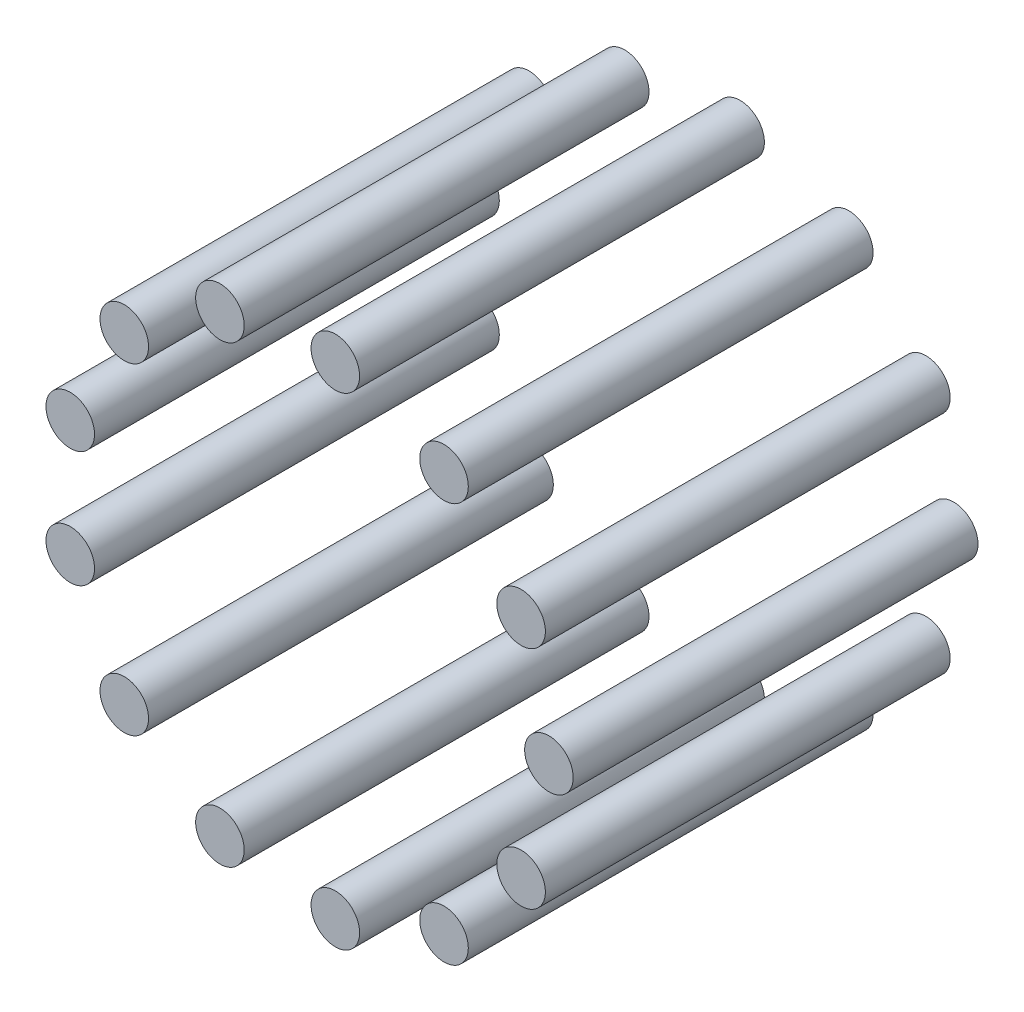
from build123d import *

# Parameters (mm, degrees)
SKETCH1_R              = 3
BOSS_EXTRUDE1_DEPTH    = 50
BOSS_EXTRUDE1_2_DEPTH  = 50
BOSS_EXTRUDE1_3_DEPTH  = 50
BOSS_EXTRUDE1_4_DEPTH  = 50
BOSS_EXTRUDE1_5_DEPTH  = 50
BOSS_EXTRUDE1_6_DEPTH  = 50
BOSS_EXTRUDE1_7_DEPTH  = 50
BOSS_EXTRUDE1_8_DEPTH  = 50
BOSS_EXTRUDE1_9_DEPTH  = 50
BOSS_EXTRUDE1_10_DEPTH = 50
BOSS_EXTRUDE1_11_DEPTH = 50
BOSS_EXTRUDE1_12_DEPTH = 50
BOSS_EXTRUDE1_13_DEPTH = 50


with BuildPart() as part:
    # Sketch1 → Boss-Extrude1 (new body)
    with BuildSketch(Plane.XY):
        with Locations((30, 0)):
            Circle(SKETCH1_R)
    extrude(amount=BOSS_EXTRUDE1_DEPTH)


with BuildPart() as body_2:
    # Sketch1 → Boss-Extrude1 2 (new body)
    with BuildSketch(Plane.XY):
        with Locations((26.56368077, -13.941695161)):
            Circle(SKETCH1_R)
    extrude(amount=BOSS_EXTRUDE1_2_DEPTH)


with BuildPart() as body_3:
    # Sketch1 → Boss-Extrude1 3 (new body)
    with BuildSketch(Plane.XY):
        with Locations((17.041942402, -24.689515977)):
            Circle(SKETCH1_R)
    extrude(amount=BOSS_EXTRUDE1_3_DEPTH)


with BuildPart() as body_4:
    # Sketch1 → Boss-Extrude1 4 (new body)
    with BuildSketch(Plane.XY):
        with Locations((3.616100408, -29.781266223)):
            Circle(SKETCH1_R)
    extrude(amount=BOSS_EXTRUDE1_4_DEPTH)


with BuildPart() as body_5:
    # Sketch1 → Boss-Extrude1 5 (new body)
    with BuildSketch(Plane.XY):
        with Locations((-10.638146611, -28.050487281)):
            Circle(SKETCH1_R)
    extrude(amount=BOSS_EXTRUDE1_5_DEPTH)


with BuildPart() as body_6:
    # Sketch1 → Boss-Extrude1 6 (new body)
    with BuildSketch(Plane.XY):
        with Locations((-22.455322445, -19.893679747)):
            Circle(SKETCH1_R)
    extrude(amount=BOSS_EXTRUDE1_6_DEPTH)


with BuildPart() as body_7:
    # Sketch1 → Boss-Extrude1 7 (new body)
    with BuildSketch(Plane.XY):
        with Locations((-29.128254523, -7.179469929)):
            Circle(SKETCH1_R)
    extrude(amount=BOSS_EXTRUDE1_7_DEPTH)


with BuildPart() as body_8:
    # Sketch1 → Boss-Extrude1 8 (new body)
    with BuildSketch(Plane.XY):
        with Locations((-29.128254523, 7.179469929)):
            Circle(SKETCH1_R)
    extrude(amount=BOSS_EXTRUDE1_8_DEPTH)


with BuildPart() as body_9:
    # Sketch1 → Boss-Extrude1 9 (new body)
    with BuildSketch(Plane.XY):
        with Locations((-22.455322445, 19.893679747)):
            Circle(SKETCH1_R)
    extrude(amount=BOSS_EXTRUDE1_9_DEPTH)


with BuildPart() as body_10:
    # Sketch1 → Boss-Extrude1 10 (new body)
    with BuildSketch(Plane.XY):
        with Locations((-10.638146611, 28.050487281)):
            Circle(SKETCH1_R)
    extrude(amount=BOSS_EXTRUDE1_10_DEPTH)


with BuildPart() as body_11:
    # Sketch1 → Boss-Extrude1 11 (new body)
    with BuildSketch(Plane.XY):
        with Locations((3.616100408, 29.781266223)):
            Circle(SKETCH1_R)
    extrude(amount=BOSS_EXTRUDE1_11_DEPTH)


with BuildPart() as body_12:
    # Sketch1 → Boss-Extrude1 12 (new body)
    with BuildSketch(Plane.XY):
        with Locations((17.041942402, 24.689515977)):
            Circle(SKETCH1_R)
    extrude(amount=BOSS_EXTRUDE1_12_DEPTH)


with BuildPart() as body_13:
    # Sketch1 → Boss-Extrude1 13 (new body)
    with BuildSketch(Plane.XY):
        with Locations((26.56368077, 13.941695161)):
            Circle(SKETCH1_R)
    extrude(amount=BOSS_EXTRUDE1_13_DEPTH)


solid = Compound([part.part, body_2.part, body_3.part, body_4.part, body_5.part, body_6.part, body_7.part, body_8.part, body_9.part, body_10.part, body_11.part, body_12.part, body_13.part])
